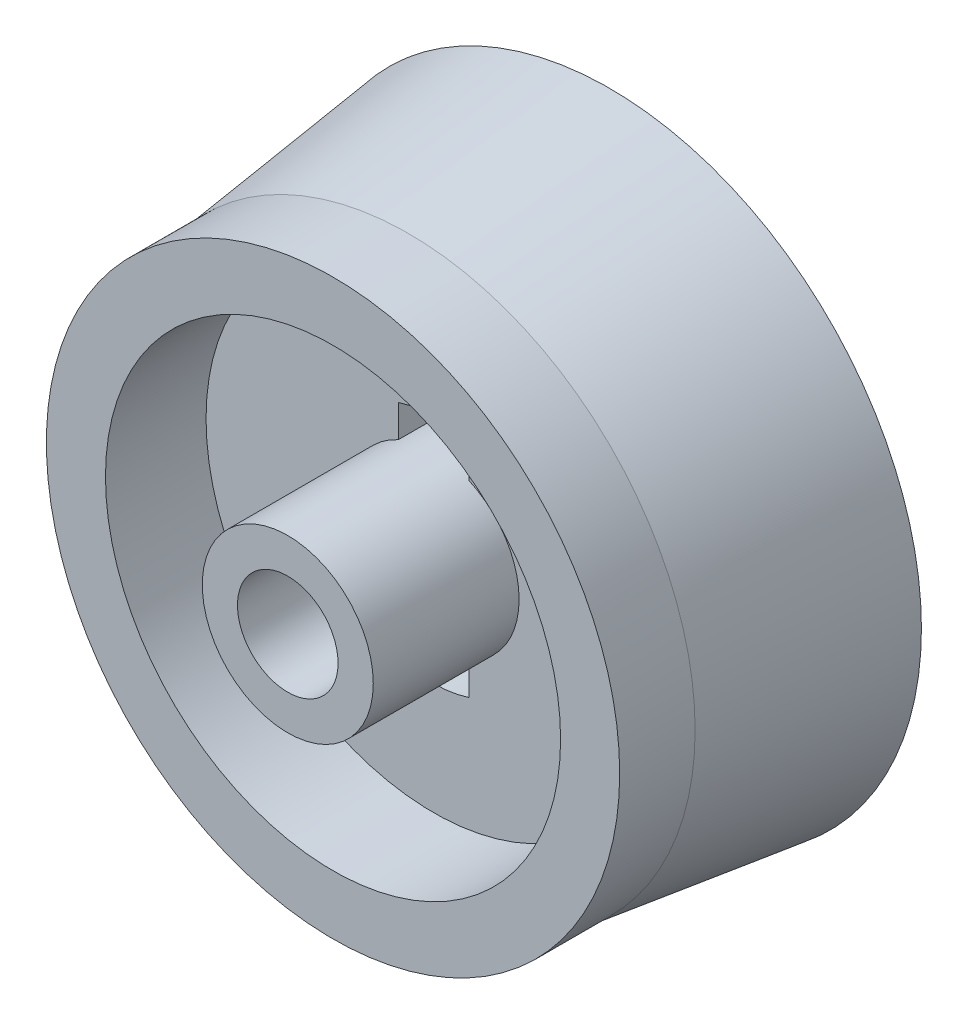
from build123d import *

# Parameters (mm, degrees)
SKETCH_1_R           = 1.7
SKETCH_1_R_2         = 1
EXTRUDE_1_DEPTH      = 0.9
EXTRUDE_1_DEPTH_BACK = 2
SKETCH_1_3_R         = 5.7
SKETCH_1_3_R_2       = 4.525
EXTRUDE_2_DEPTH      = 1.5
SKETCH_2_R           = 5
EXTRUDE_3_DEPTH      = 1.2
SKETCH_2_5_R         = 1
CUT_EXTRUDE_3_DEPTH  = 2.2
SKETCH_6_R           = 1.15
CUT_EXTRUDE_4_DEPTH  = 0.9
SKETCH_4_W           = 0.5
SKETCH_4_H           = 0.375
SKETCH_7_R           = 5.325
CUT_EXTRUDE_5_DEPTH  = 0.7


with BuildPart() as part:
    # Sketch 1 → Extrude 1 (new body, two sides)
    with BuildSketch(Plane.XY) as extrude_1_sk:
        Circle(SKETCH_1_R)
        Circle(SKETCH_1_R_2, mode=Mode.SUBTRACT)
    extrude(amount=EXTRUDE_1_DEPTH)
    extrude(extrude_1_sk.sketch, amount=-EXTRUDE_1_DEPTH_BACK)

    # Sketch 2 → Extrude 3 (add)
    with BuildSketch(Plane(origin=(0, 0, -2), x_dir=(-1, 0, 0), z_dir=(0, 0, -1))):
        Circle(SKETCH_2_R)
    extrude(amount=EXTRUDE_3_DEPTH)

    # Sketch 2_5 → Cut-Extrude 3 (cut, through all)
    with BuildSketch(Plane(origin=(0, 0, -2), x_dir=(-1, 0, 0), z_dir=(0, 0, -1))):
        with BuildLine():
            Line((-0.7, -1.549193338), (-0.7, -2.19089023))
            ThreePointArc((-0.7, -2.19089023), (0, -2.3), (0.7, -2.19089023))
            Line((0.7, -2.19089023), (0.7, -1.549193338))
            ThreePointArc((0.7, -1.549193338), (0, -1.7), (-0.7, -1.549193338))
        make_face()
        with BuildLine():
            ThreePointArc((0.7, 2.19089023), (0, 2.3), (-0.7, 2.19089023))
            Line((-0.7, 2.19089023), (-0.7, 1.549193338))
            ThreePointArc((-0.7, 1.549193338), (0, 1.7), (0.7, 1.549193338))
            Line((0.7, 1.549193338), (0.7, 2.19089023))
        make_face()
        with BuildLine():
            Line((-0.7, -1.549193338), (-0.7, -2.19089023))
            ThreePointArc((-0.7, -2.19089023), (0, -2.3), (0.7, -2.19089023))
            Line((0.7, -2.19089023), (0.7, -1.549193338))
            ThreePointArc((0.7, -1.549193338), (0, -1.7), (-0.7, -1.549193338))
        make_face()
        with BuildLine():
            ThreePointArc((0.7, 2.19089023), (0, 2.3), (-0.7, 2.19089023))
            Line((-0.7, 2.19089023), (-0.7, 1.549193338))
            ThreePointArc((-0.7, 1.549193338), (0, 1.7), (0.7, 1.549193338))
            Line((0.7, 1.549193338), (0.7, 2.19089023))
        make_face()
        with Locations(Location((0, 0, 0), (0, 0, 180))):  # turned: the seam where the file's is
            Circle(SKETCH_2_5_R)
    extrude(amount=CUT_EXTRUDE_3_DEPTH, mode=Mode.SUBTRACT)

    # Sketch 6 → Cut-Extrude 4 (cut)
    with BuildSketch(Plane(origin=(0, 0, -3.2), x_dir=(-1, 0, 0), z_dir=(0, 0, -1))):
        Circle(SKETCH_6_R)
    extrude(amount=-CUT_EXTRUDE_4_DEPTH, mode=Mode.SUBTRACT)



with BuildPart() as body_2:
    # Sketch 1_3 → Extrude 2 (new body)
    with BuildSketch(Plane.XY):
        Circle(SKETCH_1_3_R)
        Circle(SKETCH_1_3_R_2, mode=Mode.SUBTRACT)
    extrude(amount=-EXTRUDE_2_DEPTH)


with BuildPart() as part_1:
    add(part.part)

    add(body_2.part)  # Revolve 2 merges body 2
    # Sketch 4 → Revolve 2 (revolve)
    with BuildSketch(Plane(origin=(0, 0, 0), x_dir=(0, 0, -1), z_dir=(1, 0, 0)), mode=Mode.PRIVATE) as revolve_2_sk:
        Polygon((1.5, 5.7), (5.5, 6.2), (5.5, 4.9), (1.5, 4.9), align=None)
        with Locations((1.75, 4.7125)):
            Rectangle(SKETCH_4_W, SKETCH_4_H)
    revolve(revolve_2_sk.sketch.rotate(Axis((0, 0, 1000), (0, 0, -1)), 90), axis=Axis((0, 0, 1000), (0, 0, -1)))  # turned: the seam where the file's is

    # Sketch 7 → Cut-Extrude 5 (cut)
    with BuildSketch(Plane(origin=(0, 0, -5.5), x_dir=(-1, 0, 0), z_dir=(0, 0, -1))):
        Circle(SKETCH_7_R)
    extrude(amount=-CUT_EXTRUDE_5_DEPTH, mode=Mode.SUBTRACT)


solid = part_1.part
